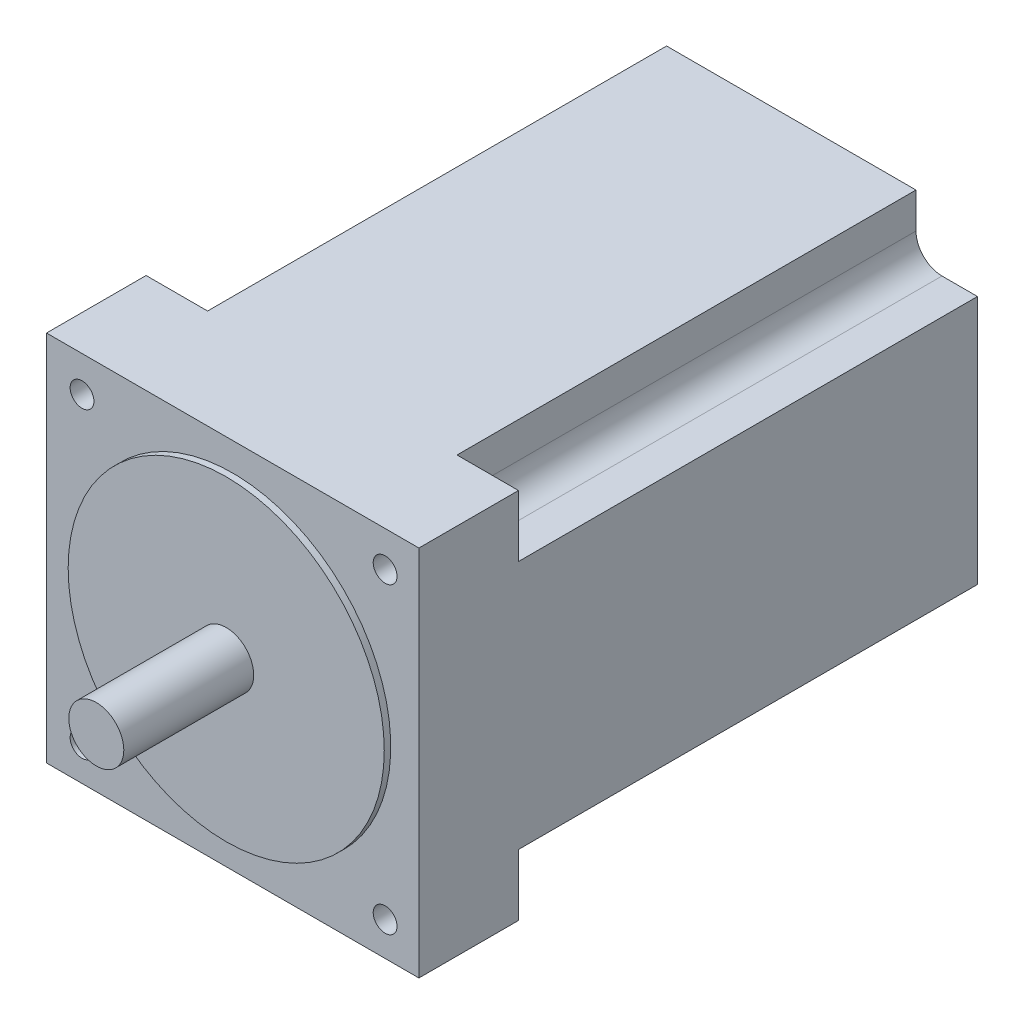
from build123d import *

# Parameters (mm, degrees)
SKETCH_3_W               = 86
SKETCH_3_H               = 86
EXTRUDE_2_DEPTH          = 64.5
CUT_EXTRUDE_2_DEPTH      = 106
PATTERN_CIRCULAR_1_COUNT = 4
SKETCH_5_R               = 2.75
CUT_EXTRUDE_3_DEPTH      = 10
SKETCH_6_R               = 36.5
EXTRUDE_3_DEPTH          = 1.5
SKETCH_7_R               = 6.35
EXTRUDE_4_DEPTH          = 30


with BuildPart() as part:
    # 草图3 → 凸台-拉伸2 (new, symmetric)
    with BuildSketch(Plane.XY):
        Rectangle(SKETCH_3_W, SKETCH_3_H)
    extrude(amount=EXTRUDE_2_DEPTH, both=True)

    # 草图4 → 切除-拉伸2 (cut)
    with BuildSketch(Plane(origin=(0, 0, -64.5), x_dir=(-1, 0, 0), z_dir=(0, 0, -1))):
        with BuildLine():
            Line((-28.8, 34.8), (-28.8, 43))
            Line((-28.8, 43), (-43, 43))
            Line((-43, 43), (-43, 28.8))
            Line((-43, 28.8), (-34.8, 28.8))
            ThreePointArc((-34.8, 28.8), (-30.557359313, 30.557359313), (-28.8, 34.8))
        make_face()
    cut_extrude_2 = extrude(amount=-CUT_EXTRUDE_2_DEPTH, mode=Mode.SUBTRACT)

    # 阵列(圆周)1: 切除-拉伸2 ×4 about axis
    pattern_circular_1_axis = Axis((0, 0, -44), (0, 0, 1))
    for i in range(1, PATTERN_CIRCULAR_1_COUNT):
        add(cut_extrude_2.rotate(pattern_circular_1_axis, i * 360 / PATTERN_CIRCULAR_1_COUNT), mode=Mode.SUBTRACT)

    # 草图5 → 切除-拉伸3 (cut)
    with BuildSketch(Plane.XY.offset(64.5)):
        with Locations((-34.8, 34.8)):
            Circle(SKETCH_5_R)
        with Locations((35.2, 34.8)):
            Circle(SKETCH_5_R)
        with Locations((35.2, -35.2)):
            Circle(SKETCH_5_R)
        with Locations((-34.8, -35.2)):
            Circle(SKETCH_5_R)
    extrude(amount=-CUT_EXTRUDE_3_DEPTH, mode=Mode.SUBTRACT)

    # 草图6 → 凸台-拉伸3 (add)
    with BuildSketch(Plane.XY.offset(64.5)):
        Circle(SKETCH_6_R)
    extrude(amount=EXTRUDE_3_DEPTH)

    # 草图7 → 凸台-拉伸4 (add)
    with BuildSketch(Plane.XY.offset(66)):
        Circle(SKETCH_7_R)
    extrude(amount=EXTRUDE_4_DEPTH)


solid = part.part
